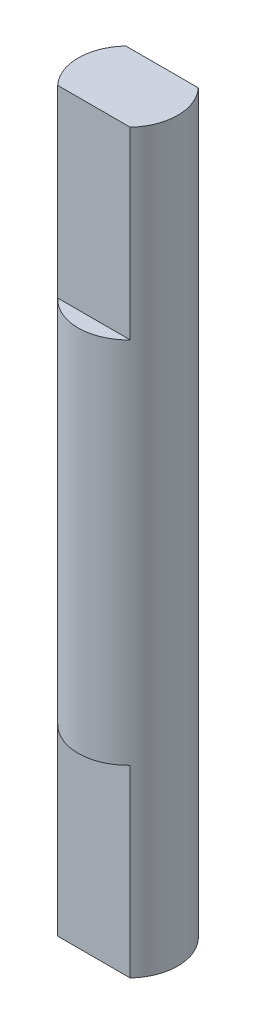
from build123d import *

# Parameters (mm, degrees)
CROQUIS1_R              = 2.7
SALIENTE_EXTRUIR1_DEPTH = 10
SALIENTE_EXTRUIR2_DEPTH = 10


with BuildPart() as part:
    # Croquis1 → Saliente-Extruir1 (new body, symmetric)
    with BuildSketch(Plane(origin=(0, 0, 0), x_dir=(1, 0, 0), z_dir=(0, 1, 0))):
        Circle(CROQUIS1_R)
    extrude(amount=SALIENTE_EXTRUIR1_DEPTH, both=True)

    # Croquis2 → Saliente-Extruir2 (add)
    with BuildSketch(Plane(origin=(0, 10, 0), x_dir=(1, 0, 0), z_dir=(0, 1, 0))):
        with BuildLine():
            Line((1.966596, 1.85), (-1.966596, 1.85))
            ThreePointArc((-1.966596, 1.85), (-2.7, 0), (-1.966596, -1.85))
            Line((-1.966596, -1.85), (1.966596, -1.85))
            ThreePointArc((1.966596, -1.85), (2.7, 0), (1.966596, 1.85))
        make_face()
    saliente_extruir2 = extrude(amount=SALIENTE_EXTRUIR2_DEPTH)

    # Simetría1: Saliente-Extruir2 across plane
    add(saliente_extruir2.mirror(Plane.ZX))


solid = part.part
